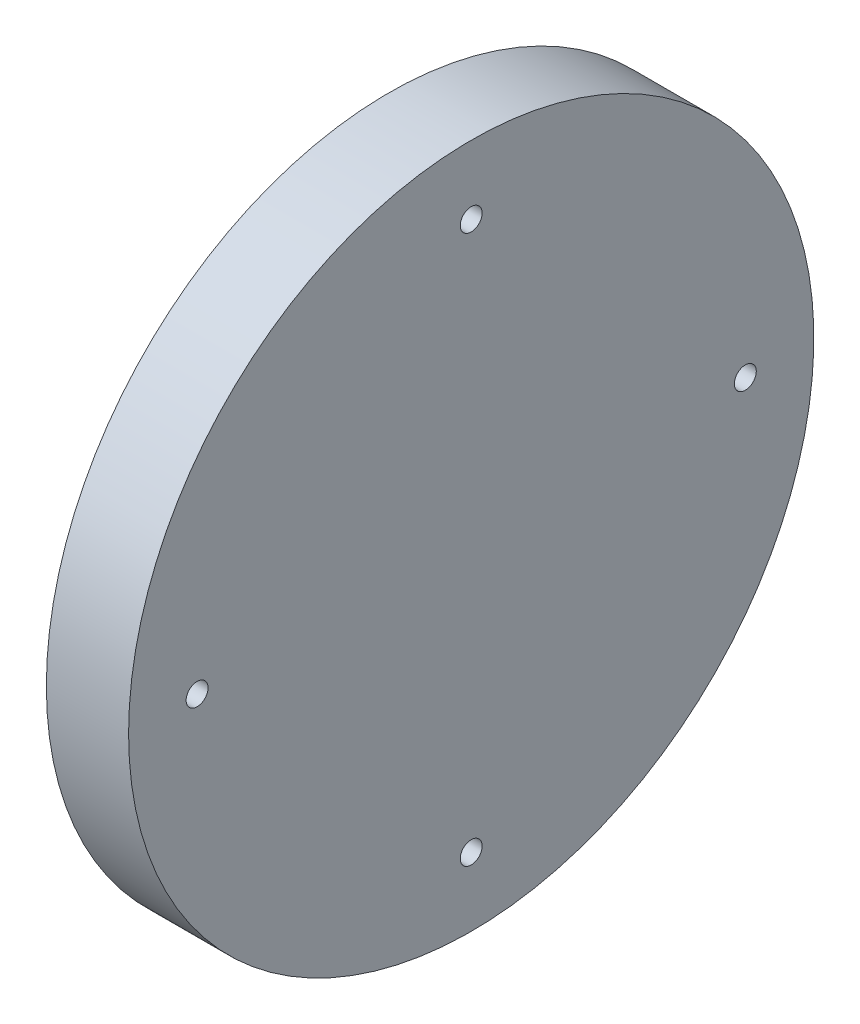
from build123d import *

# Parameters (mm, degrees)
SKETCH_1_W                  = 6
SKETCH_1_H                  = 25
SKETCH_2_R                  = 9.5
EXTRUDE_1_DEPTH             = 5
HOLE_WIZARD_1_6_1_6_1_D     = 1.6
HOLE_WIZARD_1_6_1_6_1_DEPTH = 6


with BuildPart() as part:
    # 스케치1 → 회전1 (revolve)
    with BuildSketch(Plane(origin=(0, 0, 0), x_dir=(-1, 0, 0), z_dir=(0, 0, -1))):
        with Locations((-8, 12.5)):
            Rectangle(SKETCH_1_W, SKETCH_1_H)
    revolve(axis=Axis((11, 0, 0), (-1, 0, 0)))

    # 스케치2 → 보스-돌출1 (add)
    with BuildSketch(Plane.ZY.offset(-5)):
        Circle(SKETCH_2_R)
    extrude(amount=EXTRUDE_1_DEPTH)

    # Ø1.6 (1.6) 지름 구멍1
    with Locations(Plane.ZY.offset(-5)):
        with Locations((0, 20), (-20, 0), (0, -20), (20, 0)):
            Hole(HOLE_WIZARD_1_6_1_6_1_D / 2, depth=HOLE_WIZARD_1_6_1_6_1_DEPTH)


solid = part.part
